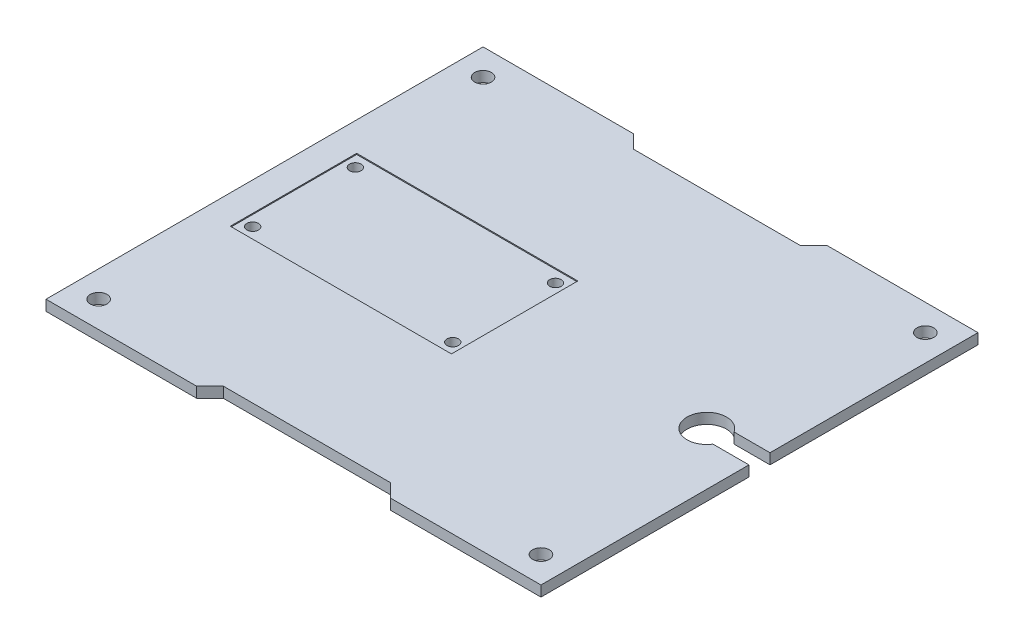
from build123d import *

# Parameters (mm, degrees)
SKETCH1_W           = 94
SKETCH1_H           = 83
SKETCH1_R           = 1.5875
BOSS_EXTRUDE1_DEPTH = 2
SKETCH2_R           = 1.1
CUT_EXTRUDE1_DEPTH  = 10
SKETCH3_W           = 42
SKETCH3_H           = 24
CUT_EXTRUDE2_DEPTH  = 0.2


with BuildPart() as part:
    # Sketch1 → Boss-Extrude1 (new body)
    with BuildSketch(Plane(origin=(0, 0, 0), x_dir=(1, 0, 0), z_dir=(0, 1, 0))):
        Rectangle(SKETCH1_W, SKETCH1_H)
        with Locations((-42, 36.5)):
            Circle(SKETCH1_R, mode=Mode.SUBTRACT)
        with Locations((42, 36.5)):
            Circle(SKETCH1_R, mode=Mode.SUBTRACT)
        with Locations((42, -36.5)):
            Circle(SKETCH1_R, mode=Mode.SUBTRACT)
        with Locations((-42, -36.5)):
            Circle(SKETCH1_R, mode=Mode.SUBTRACT)
    extrude(amount=BOSS_EXTRUDE1_DEPTH)

    # Sketch2 → Cut-Extrude1 (cut)
    with BuildSketch(Plane(origin=(0, 2, 0), x_dir=(1, 0, 0), z_dir=(0, 1, 0))):
        with Locations((-39.5, 9.75)):
            Circle(SKETCH2_R)
        with Locations((-1.5, 9.75)):
            Circle(SKETCH2_R)
        with Locations((-1.5, -9.75)):
            Circle(SKETCH2_R)
        with Locations((-39.5, -9.75)):
            Circle(SKETCH2_R)
        with BuildLine():
            Line((40.172144385, 2), (47, 2))
            Line((47, 2), (47, -2))
            Line((47, -2), (40.172144385, -2))
            ThreePointArc((40.172144385, -2), (33.25, 0), (40.172144385, 2))
        make_face()
        Polygon((-18.415, -41.5), (-15.875, -38.96), (15.875, -38.96), (18.415, -41.5), align=None)
        Polygon((-18.415, 41.5), (-15.875, 38.96), (15.875, 38.96), (18.415, 41.5), align=None)
    extrude(amount=-CUT_EXTRUDE1_DEPTH, mode=Mode.SUBTRACT)

    # Sketch3 → Cut-Extrude2 (cut)
    with BuildSketch(Plane(origin=(0, 2, 0), x_dir=(1, 0, 0), z_dir=(0, 1, 0))):
        with Locations((-20.5, 0)):
            Rectangle(SKETCH3_W, SKETCH3_H)
    extrude(amount=-CUT_EXTRUDE2_DEPTH, mode=Mode.SUBTRACT)


solid = part.part
